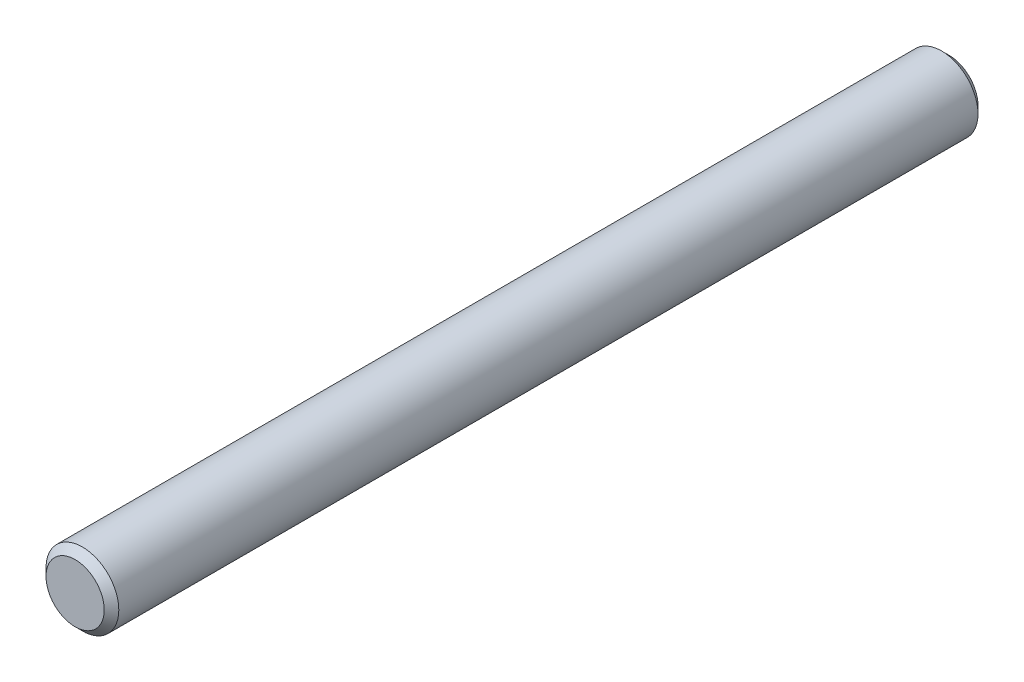
from build123d import *

# Parameters (mm, degrees)
SKETCH1_R      = 12.7
EXTRUDE1_DEPTH = 152.4
CHAMFER1_SIZE  = 2.54


with BuildPart() as part:
    # Sketch1 → Extrude1 (new body, symmetric)
    with BuildSketch(Plane.XY):
        Circle(SKETCH1_R)
    extrude(amount=EXTRUDE1_DEPTH, both=True)

    # Chamfer1
    chamfer1_edges = [part.edges().sort_by_distance(p)[0] for p in [
        (-12.7, 0, -152.4),
        (-12.7, 0, 152.4),
    ]]
    chamfer(chamfer1_edges, length=CHAMFER1_SIZE)


solid = part.part
